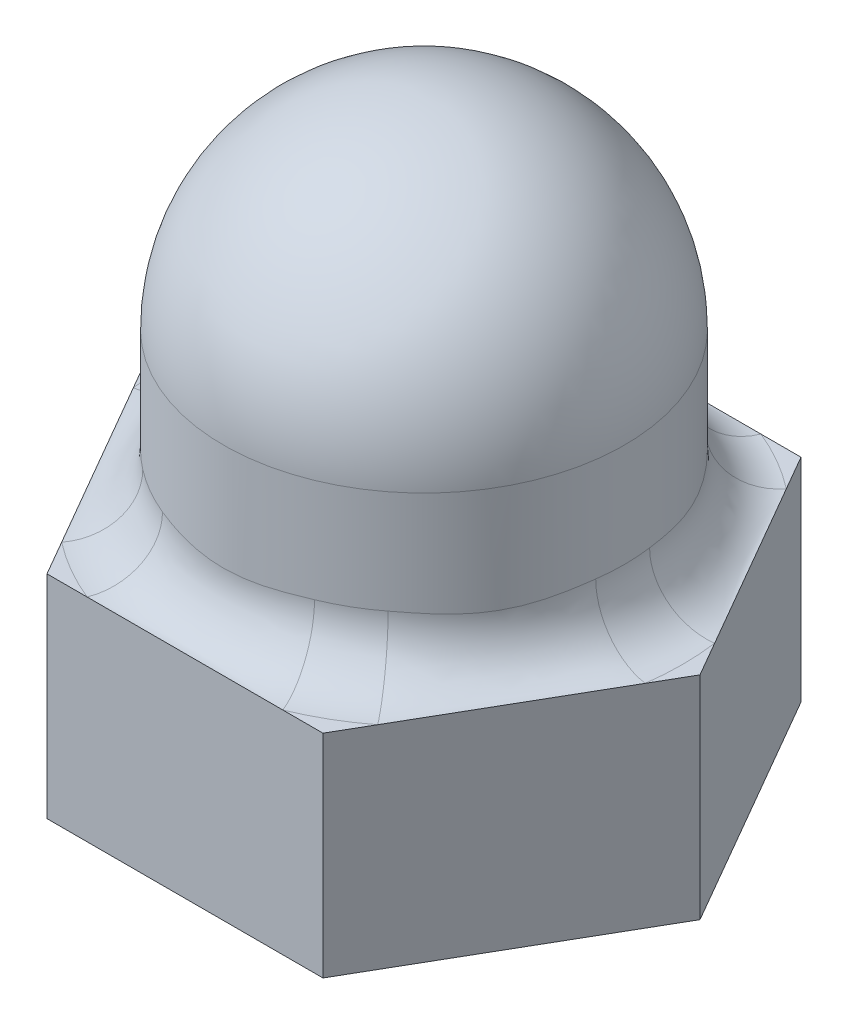
from build123d import *

# Parameters (mm, degrees)
BOSS_EXTRUDE1_DEPTH        = 3.4925
F_12_28_TAPPED_HOLE1_D     = 4.6228
F_12_28_TAPPED_HOLE1_DEPTH = 7.62
F_12_28_TAPPED_HOLE1_TIP   = 0.407562183
FILLET2_R                  = 0.9525


with BuildPart() as part:
    # Sketch1 → Revolve2 (revolve)
    with BuildSketch(Plane.XY, mode=Mode.PRIVATE) as revolve2_sk:
        with BuildLine():
            Line((0, 0), (0, 9.4488))
            ThreePointArc((0, 9.4488), (-2.334866591, 8.481666591), (-3.302, 6.1468))
            Line((-3.302, 6.1468), (-3.302, 0))
            Line((-3.302, 0), (0, 0))
        make_face()
    revolve(revolve2_sk.sketch.rotate(Axis((0, 0, 0), (0, 1, 0)), 270), axis=Axis((0, 0, 0), (0, 1, 0)))

    # Sketch2 → Boss-Extrude1 (add)
    with BuildSketch(Plane.XZ):
        Polygon((4.54605602, 0), (2.27302801, 3.937), (-2.27302801, 3.937), (-4.54605602, 0), (-2.27302801, -3.937), (2.27302801, -3.937), align=None)
    extrude(amount=-BOSS_EXTRUDE1_DEPTH)

    # #12-28 Tapped Hole1
    with Locations(Plane.XZ):
        with Locations((0, 0)):
            Hole(F_12_28_TAPPED_HOLE1_D / 2, depth=F_12_28_TAPPED_HOLE1_DEPTH)
            with Locations((0, 0, -(F_12_28_TAPPED_HOLE1_DEPTH + F_12_28_TAPPED_HOLE1_TIP / 2))):  # 160° drill point
                Cone(0, F_12_28_TAPPED_HOLE1_D / 2, F_12_28_TAPPED_HOLE1_TIP, mode=Mode.SUBTRACT)

    # Fillet2
    fillet2_edges = [part.edges().sort_by_distance(p)[0] for p in [
        (0, 3.4925, 3.302),
    ]]
    fillet(fillet2_edges, radius=FILLET2_R)


solid = part.part
